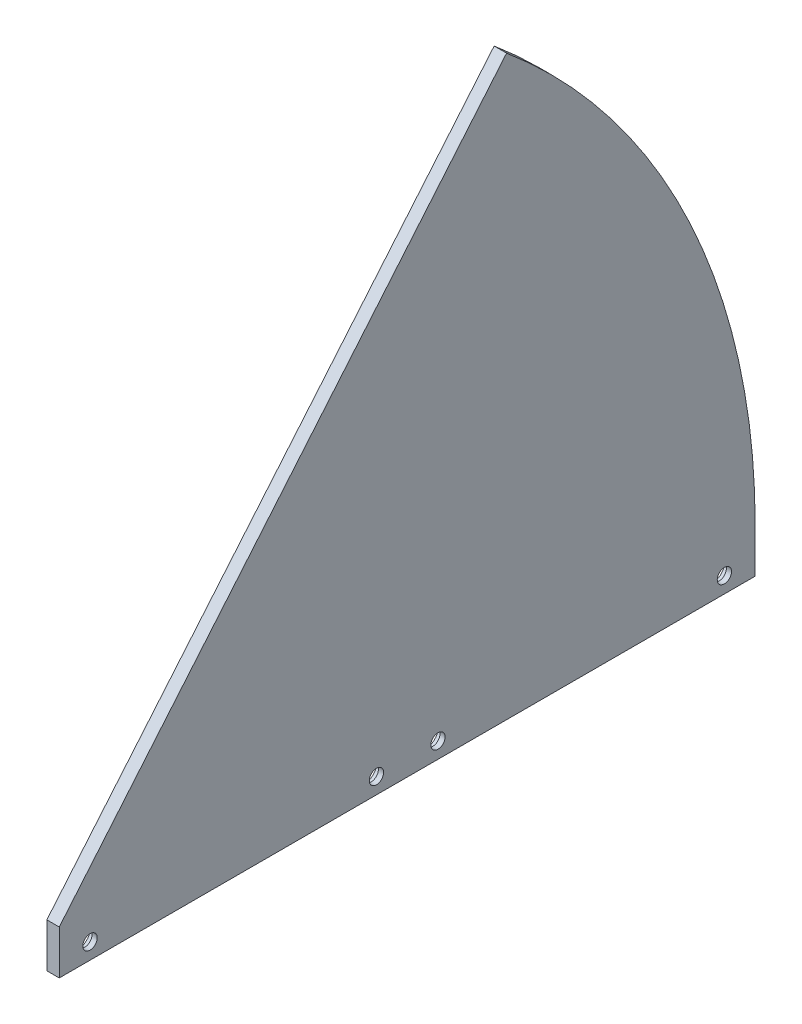
from build123d import *

# Parameters (mm, degrees)
BOSS_EXTRUDE1_DEPTH = 3.175
SKETCH2_W           = 3.175
SKETCH2_H           = 178.054
BOSS_EXTRUDE2_DEPTH = 11.303
SKETCH3_R           = 1.8288
CUT_EXTRUDE1_DEPTH  = 4.175
CUT_EXTRUDE2_DEPTH  = 3.175
BOSS_EXTRUDE3_DEPTH = 0.635
SKETCH8_R           = 3.3274
CUT_EXTRUDE3_DEPTH  = 1.8542


with BuildPart() as part:
    # Sketch1 → Boss-Extrude1 (new body)
    with BuildSketch(Plane(origin=(0, 0, 0), x_dir=(0, 0, -1), z_dir=(1, 0, 0))):
        with BuildLine():
            Line((0, 0), (178.054, 0))
            ThreePointArc((178.054, 0), (161.371726713, 75.248871976), (114.450905055, 136.397277275))
            Line((114.450905055, 136.397277275), (0, 0))
        make_face()
    extrude(amount=BOSS_EXTRUDE1_DEPTH)

    # Sketch2 → Boss-Extrude2 (add)
    with BuildSketch(Plane.XZ):
        with Locations((1.5875, -89.027)):
            Rectangle(SKETCH2_W, SKETCH2_H)
    extrude(amount=BOSS_EXTRUDE2_DEPTH)

    # Sketch3 → Cut-Extrude1 (cut, through all)
    with BuildSketch(Plane(origin=(3.175, 0, 0), x_dir=(0, 0, -1), z_dir=(1, 0, 0))):
        with Locations((7.874, -7.239)):
            Circle(SKETCH3_R)
        with Locations((81.153, -7.239)):
            Circle(SKETCH3_R)
        with Locations((96.901, -7.239)):
            Circle(SKETCH3_R)
        with Locations((170.18, -7.239)):
            Circle(SKETCH3_R)
    extrude(amount=-CUT_EXTRUDE1_DEPTH, mode=Mode.SUBTRACT)

    # Sketch6 → Cut-Extrude2 (cut)
    with BuildSketch(Plane(origin=(3.175, 0, 0), x_dir=(0, 0, -1), z_dir=(1, 0, 0))):
        with BuildLine():
            Line((165.1, 0), (165.982635189, -11.303))
            Line((165.982635189, -11.303), (160.260021408, -11.303))
            Line((160.260021408, -11.303), (161.925, 0))
            ThreePointArc((161.925, 0), (150.657864695, 59.345711137), (118.424448135, 110.432584453))
            Line((118.424448135, 110.432584453), (120.746496137, 112.597929246))
            ThreePointArc((120.746496137, 112.597929246), (153.611940474, 60.509352532), (165.1, 0))
        make_face()
    extrude(amount=-CUT_EXTRUDE2_DEPTH, mode=Mode.SUBTRACT)

    # Sketch7 → Boss-Extrude3 (add)
    with BuildSketch(Plane(origin=(3.175, 0, 0), x_dir=(0, 0, -1), z_dir=(1, 0, 0))):
        with BuildLine():
            Line((118.424448135, 110.432584453), (120.746496137, 112.597929246))
            ThreePointArc((120.746496137, 112.597929246), (153.611940474, 60.509352532), (165.1, 0))
            Line((165.1, 0), (165.982635189, -11.303))
            Line((165.982635189, -11.303), (160.260021408, -11.303))
            Line((160.260021408, -11.303), (161.925, 0))
            ThreePointArc((161.925, 0), (150.657864695, 59.345711137), (118.424448135, 110.432584453))
        make_face()
    extrude(amount=-BOSS_EXTRUDE3_DEPTH)

    # Sketch8 → Cut-Extrude3 (cut)
    with BuildSketch(Plane.ZY):
        with Locations((-170.18, -7.239)):
            Circle(SKETCH8_R)
        with Locations((-96.901, -7.239)):
            Circle(SKETCH8_R)
        with Locations((-81.153, -7.239)):
            Circle(SKETCH8_R)
        with Locations((-7.874, -7.239)):
            Circle(SKETCH8_R)
    extrude(amount=-CUT_EXTRUDE3_DEPTH, mode=Mode.SUBTRACT)


solid = part.part
